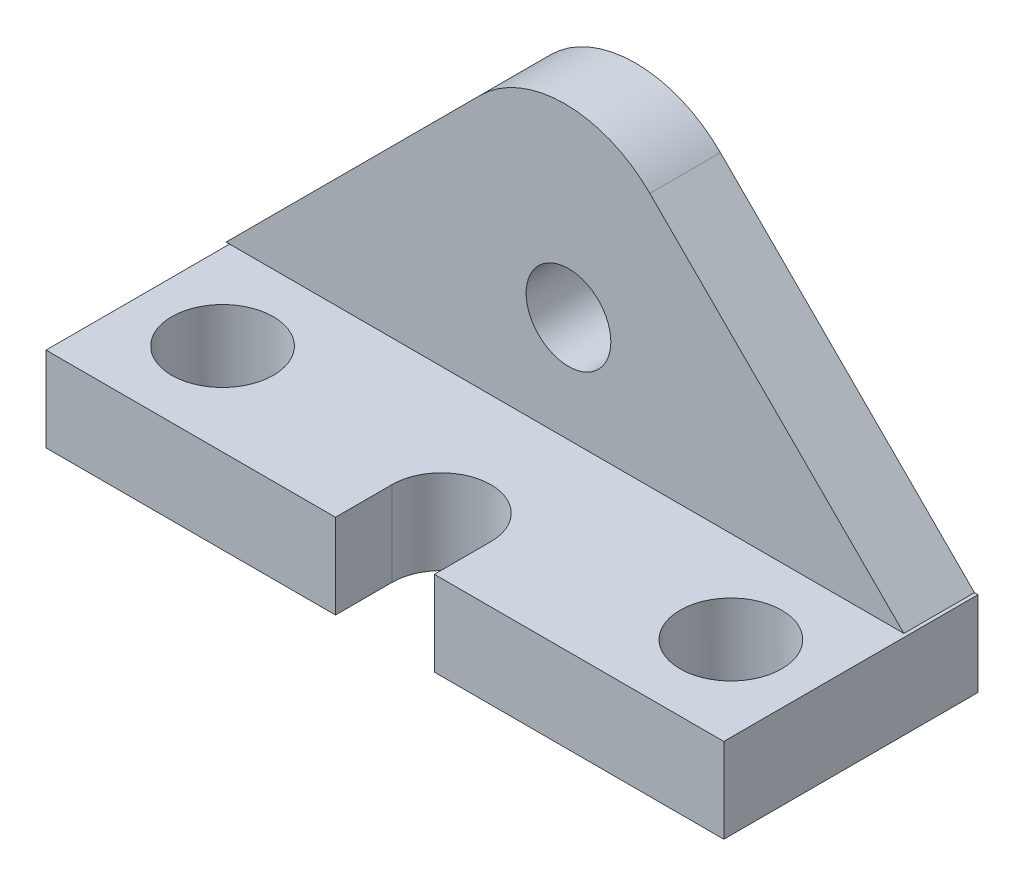
from build123d import *

# Parameters (mm, degrees)
SKETCH1_R           = 6
BOSS_EXTRUDE2_DEPTH = 5
SKETCH2_W           = 36
SKETCH2_H           = 12
BOSS_EXTRUDE3_DEPTH = 48
CUT_EXTRUDE1_DEPTH  = 48
SKETCH4_R           = 7.2
CUT_EXTRUDE2_DEPTH  = 48
SKETCH5_R           = 7.2
CUT_EXTRUDE3_DEPTH  = 48


with BuildPart() as part:
    # Sketch1 → Boss-Extrude2 (new body, symmetric)
    with BuildSketch(Plane.XY):
        with BuildLine():
            Line((-48.497409326, 0), (47.502590674, 0))
            Line((47.502590674, 0), (11.523405954, 35.97918472))
            ThreePointArc((11.523405954, 35.97918472), (-0.497409326, 40.95836944), (-12.518224607, 35.97918472))
            Line((-12.518224607, 35.97918472), (-48.497409326, 0))
        make_face()
        with Locations((0, 15)):
            Circle(SKETCH1_R, mode=Mode.SUBTRACT)
    extrude(amount=BOSS_EXTRUDE2_DEPTH, both=True)

    # Sketch2 → Boss-Extrude3 (add, symmetric)
    with BuildSketch(Plane(origin=(0, 0, 0), x_dir=(0, 0, -1), z_dir=(1, 0, 0))):
        with Locations((-13, -6)):
            Rectangle(SKETCH2_W, SKETCH2_H)
    extrude(amount=BOSS_EXTRUDE3_DEPTH, both=True)

    # Sketch3 → Cut-Extrude1 (cut, symmetric)
    with BuildSketch(Plane(origin=(0, 0, 0), x_dir=(1, 0, 0), z_dir=(0, 1, 0))):
        with BuildLine():
            Line((-7, -23), (-7, -31))
            Line((-7, -31), (7, -31))
            Line((7, -31), (7, -23))
            ThreePointArc((7, -23), (4.949747468, -18.050252532), (0, -16))
            ThreePointArc((0, -16), (-4.949747468, -18.050252532), (-7, -23))
        make_face()
    extrude(amount=CUT_EXTRUDE1_DEPTH, both=True, mode=Mode.SUBTRACT)

    # Sketch4 → Cut-Extrude2 (cut, symmetric)
    with BuildSketch(Plane(origin=(0, 0, 0), x_dir=(1, 0, 0), z_dir=(0, 1, 0))):
        with Locations((-36, -18)):
            Circle(SKETCH4_R)
    extrude(amount=CUT_EXTRUDE2_DEPTH, both=True, mode=Mode.SUBTRACT)

    # Sketch5 → Cut-Extrude3 (cut, symmetric)
    with BuildSketch(Plane(origin=(0, 0, 0), x_dir=(1, 0, 0), z_dir=(0, 1, 0))):
        with Locations((36, -18)):
            Circle(SKETCH5_R)
    extrude(amount=CUT_EXTRUDE3_DEPTH, both=True, mode=Mode.SUBTRACT)


solid = part.part
